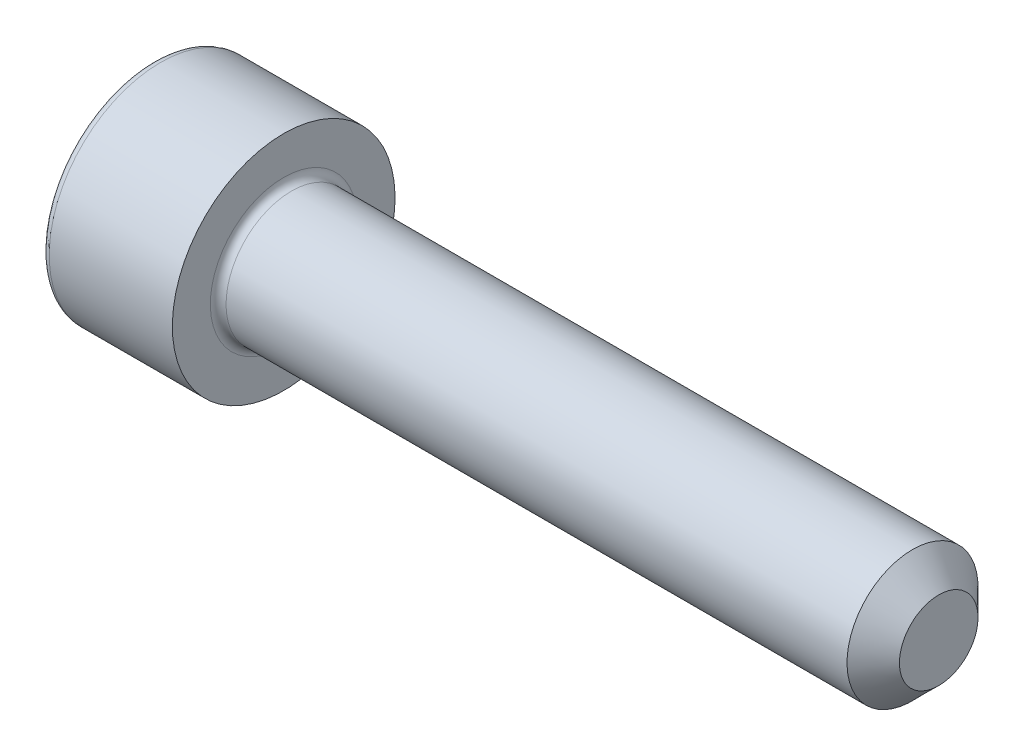
from build123d import *

# Parameters (mm, degrees)
CUT_EXTRUDE_1_DEPTH = 2.5
FILLET_1_R          = 0.3
CHAMFER_1_SIZE      = 1


with BuildPart() as part:
    # Эскиз1 → Повернуть1 (revolve)
    with BuildSketch(Plane.XY):
        Polygon((0, 0), (0, 4.25), (5, 4.25), (5, 2.5), (30, 2.5), (30, 0), align=None)
    revolve(axis=Axis((30, 0, 0), (-1, 0, 0)))

    # Эскиз2 → Вырез-Вытянуть1 (cut)
    with BuildSketch(Plane.ZY):
        Polygon((-1.154700538, 2), (-2.309401077, 0), (-1.154700538, -2), (1.154700538, -2), (2.309401077, 0), (1.154700538, 2), align=None)
    extrude(amount=-CUT_EXTRUDE_1_DEPTH, mode=Mode.SUBTRACT)

    # Скругление1
    fillet_1_edges = [part.edges().sort_by_distance(p)[0] for p in [
        (5, -2.5, 0),
        (0, -4.25, 0),
    ]]
    fillet(fillet_1_edges, radius=FILLET_1_R)

    # Фаска1
    chamfer_1_edges = [part.edges().sort_by_distance(p)[0] for p in [
        (30, -2.5, 0),
    ]]
    chamfer(chamfer_1_edges, length=CHAMFER_1_SIZE)


solid = part.part
